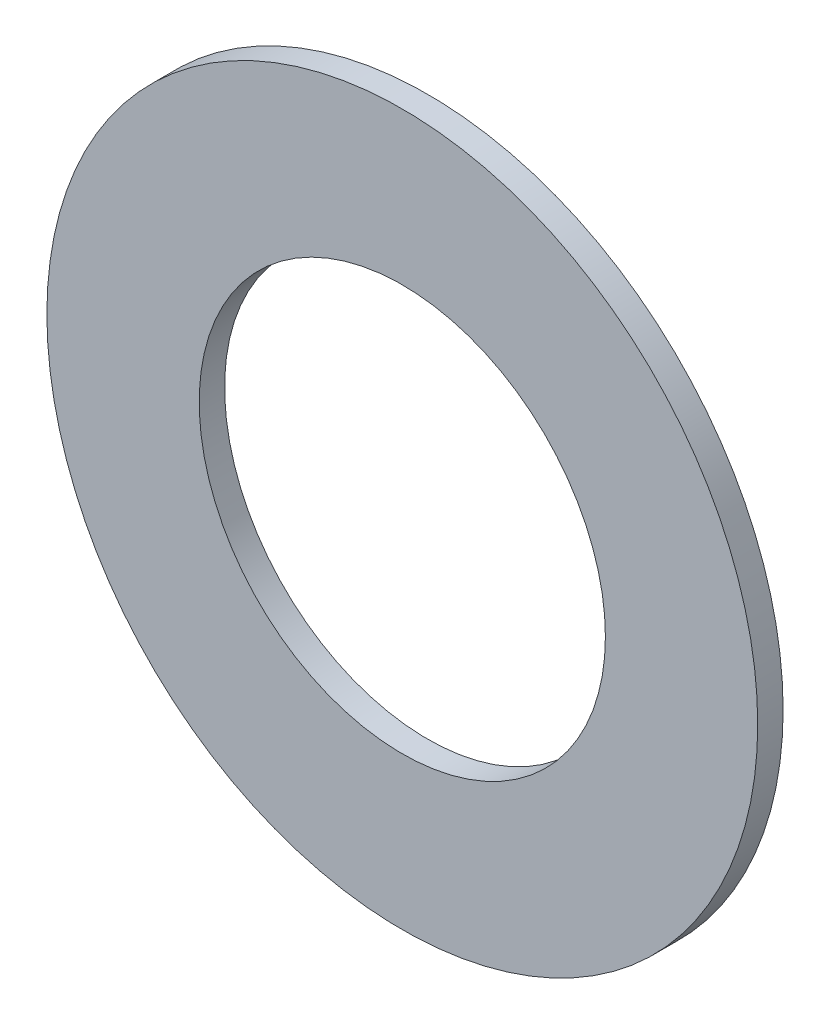
from build123d import *

# Parameters (mm, degrees)
SKETCH1_R           = 7
SKETCH1_R_2         = 4
BOSS_EXTRUDE1_DEPTH = 0.5


with BuildPart() as part:
    # Sketch1 → Boss-Extrude1 (new body)
    with BuildSketch(Plane.XY):
        Circle(SKETCH1_R)
        Circle(SKETCH1_R_2, mode=Mode.SUBTRACT)
    extrude(amount=BOSS_EXTRUDE1_DEPTH)


solid = part.part
